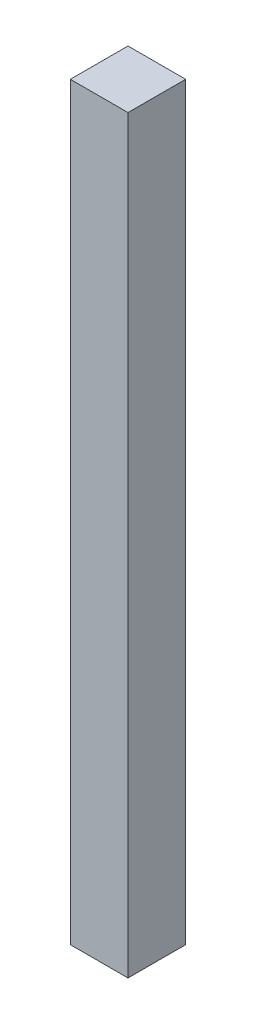
from build123d import *

# Parameters (mm, degrees)
CROQUIS1_W              = 38.1
CROQUIS1_H              = 38.1
SALIENTE_EXTRUIR1_DEPTH = 495.3
CROQUIS2_R              = 6.35
SALIENTE_EXTRUIR2_DEPTH = 12.7


with BuildPart() as part:
    # Croquis1 → Saliente-Extruir1 (new body)
    with BuildSketch(Plane(origin=(0, 0, 0), x_dir=(1, 0, 0), z_dir=(0, 1, 0))):
        Rectangle(CROQUIS1_W, CROQUIS1_H)
    extrude(amount=SALIENTE_EXTRUIR1_DEPTH)

    # Croquis2 → Saliente-Extruir2 (add)
    with BuildSketch(Plane.XZ):
        Circle(CROQUIS2_R)
    extrude(amount=SALIENTE_EXTRUIR2_DEPTH)


solid = part.part
